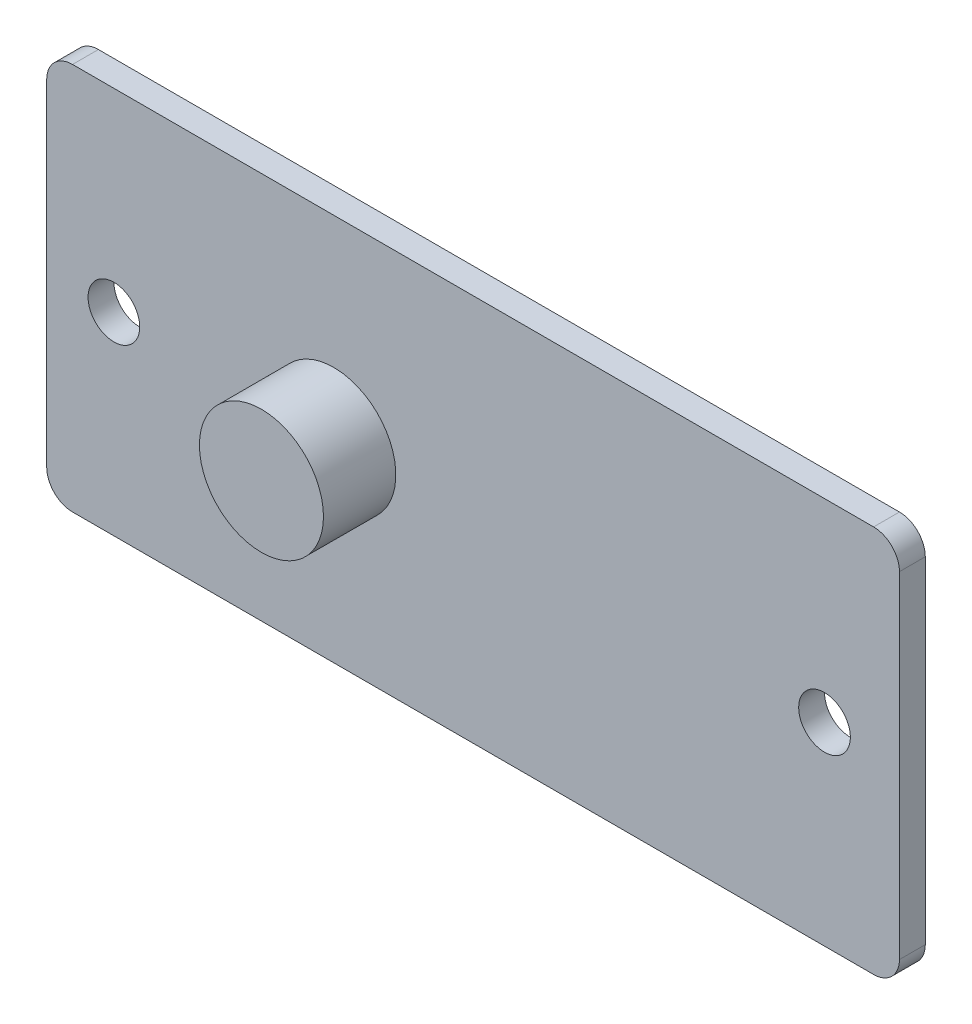
from build123d import *

# Parameters (mm, degrees)
SKETCH1_R           = 1
BOSS_EXTRUDE1_DEPTH = 1
SKETCH2_R           = 2.4
BOSS_EXTRUDE2_DEPTH = 2.8


with BuildPart() as part:
    # Sketch1 → Boss-Extrude1 (new body)
    with BuildSketch(Plane.XY):
        with BuildLine():
            Line((-15.5, 7.5), (15.5, 7.5))
            ThreePointArc((15.5, 7.5), (16.207106781, 7.207106781), (16.5, 6.5))
            Line((16.5, 6.5), (16.5, -6.5))
            ThreePointArc((16.5, -6.5), (16.207106781, -7.207106781), (15.5, -7.5))
            Line((15.5, -7.5), (-15.5, -7.5))
            ThreePointArc((-15.5, -7.5), (-16.207106781, -7.207106781), (-16.5, -6.5))
            Line((-16.5, -6.5), (-16.5, 6.5))
            ThreePointArc((-16.5, 6.5), (-16.207106781, 7.207106781), (-15.5, 7.5))
        make_face()
        with Locations((-13.9, 0)):
            Circle(SKETCH1_R, mode=Mode.SUBTRACT)
        with Locations((13.6, 0)):
            Circle(SKETCH1_R, mode=Mode.SUBTRACT)
    extrude(amount=BOSS_EXTRUDE1_DEPTH)

    # Sketch2 → Boss-Extrude2 (add)
    with BuildSketch(Plane.XY.offset(1)):
        with Locations((-5.39, 0)):
            Circle(SKETCH2_R)
    extrude(amount=BOSS_EXTRUDE2_DEPTH)


solid = part.part
